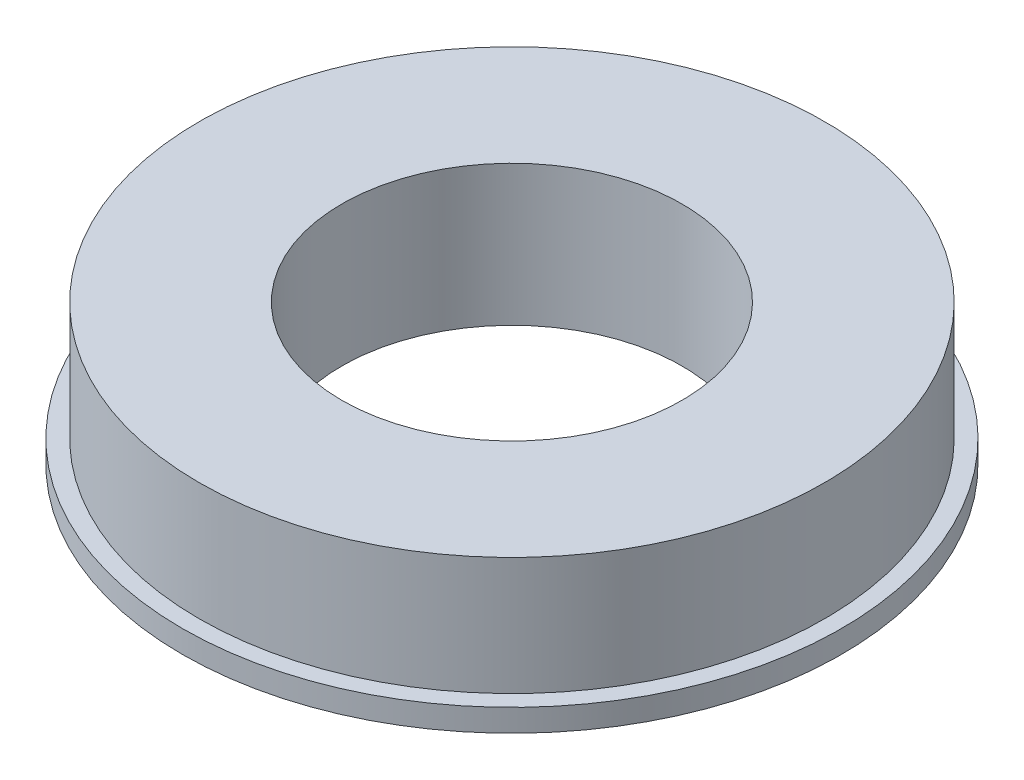
from build123d import *

# Parameters (mm, degrees)
SKETCH1_R           = 27.85
SKETCH1_R_2         = 15.15
BOSS_EXTRUDE1_DEPTH = 12.5
BOSS_EXTRUDE3_START = -12.5
SKETCH3_R           = 29.35
SKETCH3_R_2         = 27.85
BOSS_EXTRUDE3_DEPTH = 2


with BuildPart() as part:
    # Sketch1 → Boss-Extrude1 (new body)
    with BuildSketch(Plane(origin=(0, 0, 0), x_dir=(1, 0, 0), z_dir=(0, 1, 0))):
        Circle(SKETCH1_R)
        Circle(SKETCH1_R_2, mode=Mode.SUBTRACT)
    extrude(amount=BOSS_EXTRUDE1_DEPTH)

    # Sketch3 → Boss-Extrude3 (add)
    with BuildSketch(Plane(origin=(0, 12.5, 0), x_dir=(1, 0, 0), z_dir=(0, 1, 0)).offset(BOSS_EXTRUDE3_START)):
        Circle(SKETCH3_R)
        Circle(SKETCH3_R_2, mode=Mode.SUBTRACT)
    extrude(amount=BOSS_EXTRUDE3_DEPTH)


solid = part.part
